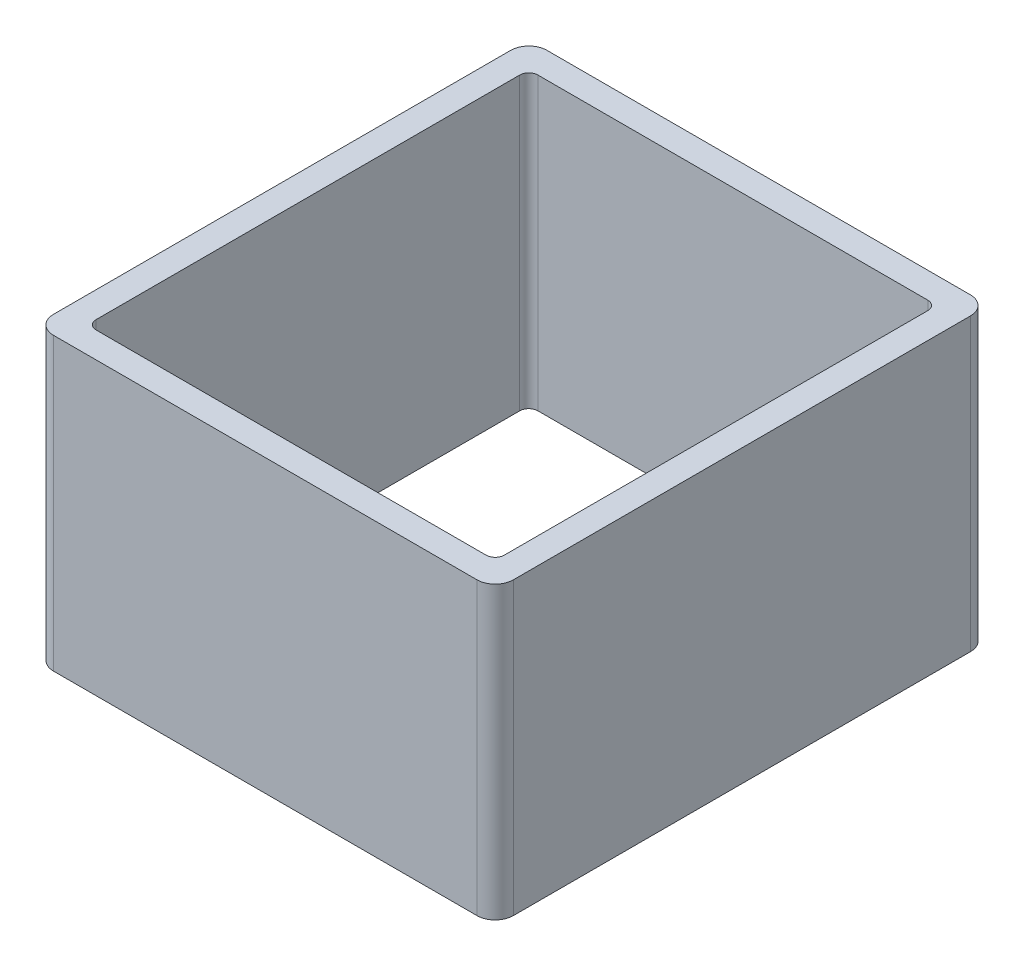
from build123d import *

# Parameters (mm, degrees)
SKETCH3_W           = 50.6
SKETCH3_H           = 54.3
SKETCH3_W_2         = 44.9
SKETCH3_H_2         = 48.6
BOSS_EXTRUDE1_DEPTH = 32
FILLET1_R           = 2
FILLET2_R           = 1


with BuildPart() as part:
    # Sketch3 → Boss-Extrude1 (new body)
    with BuildSketch(Plane(origin=(0, 0, 0), x_dir=(1, 0, 0), z_dir=(0, 1, 0))):
        Rectangle(SKETCH3_W, SKETCH3_H)
        Rectangle(SKETCH3_W_2, SKETCH3_H_2, mode=Mode.SUBTRACT)
    extrude(amount=BOSS_EXTRUDE1_DEPTH)

    # Fillet1
    fillet1_edges = [part.edges().sort_by_distance(p)[0] for p in [
        (25.3, 16, 27.15),
        (-25.3, 16, 27.15),
        (-25.3, 16, -27.15),
        (25.3, 16, -27.15),
    ]]
    fillet(fillet1_edges, radius=FILLET1_R)

    # Fillet2
    fillet2_edges = [part.edges().sort_by_distance(p)[0] for p in [
        (22.45, 16, 24.3),
        (22.45, 16, -24.3),
        (-22.45, 16, -24.3),
        (-22.45, 16, 24.3),
    ]]
    fillet(fillet2_edges, radius=FILLET2_R)


solid = part.part
